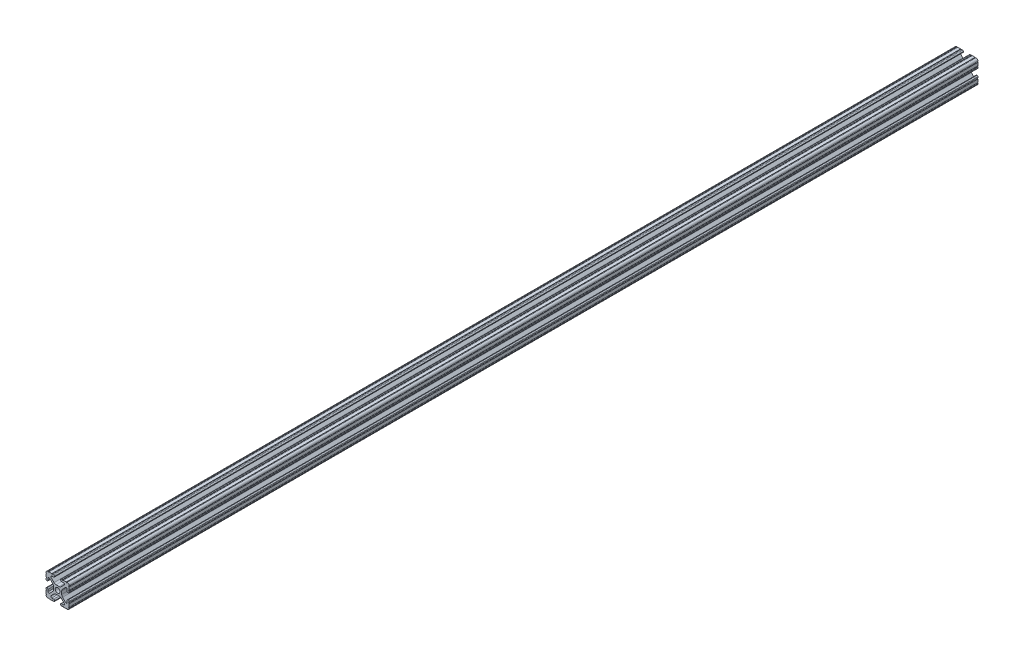
from build123d import *

# Parameters (mm, degrees)
SKETCH1_R           = 2.6035
BOSS_EXTRUDE1_DEPTH = 497.9


with BuildPart() as part:
    # Sketch1 → Boss-Extrude1 (new body, symmetric)
    with BuildSketch(Plane.XY):
        with BuildLine():
            Line((-7.179650497, -8.645192506), (-3.952270251, -5.423690499))
            ThreePointArc((-3.952270251, -5.423690499), (-2.922936451, -4.736929036), (-1.709253557, -4.4958))
            Line((-1.709253557, -4.4958), (1.709253557, -4.4958))
            ThreePointArc((1.709253557, -4.4958), (2.922936451, -4.736929036), (3.952270251, -5.423690499))
            Line((3.952270251, -5.423690499), (7.179650497, -8.645192506))
            ThreePointArc((7.179650497, -8.645192506), (7.41473083, -9.822813117), (6.416408329, -10.4902))
            Line((6.416408329, -10.4902), (4.287512407, -10.4902))
            ThreePointArc((4.287512407, -10.4902), (3.54574862, -10.79744862), (3.2385, -11.539212407))
            Line((3.2385, -11.539212407), (3.2385, -11.650987593))
            ThreePointArc((3.2385, -11.650987593), (3.54574862, -12.39275138), (4.287512407, -12.7))
            Line((4.287512407, -12.7), (5.317126718, -12.7))
            ThreePointArc((5.317126718, -12.7), (5.825126718, -12.192), (6.333126718, -12.7))
            Line((6.333126718, -12.7), (9.550443118, -12.7))
            ThreePointArc((9.550443118, -12.7), (10.058366869, -12.192000006), (10.566443095, -12.699847501))
            ThreePointArc((10.566443095, -12.699847501), (12.082537762, -12.08250727), (12.699846982, -10.566399977))
            ThreePointArc((12.699846982, -10.566399977), (12.192000006, -10.058323491), (12.7, -9.5504))
            Line((12.7, -9.5504), (12.7, -6.3330836))
            ThreePointArc((12.7, -6.3330836), (12.192, -5.8250836), (12.7, -5.3170836))
            Line((12.7, -5.3170836), (12.7, -4.287469289))
            ThreePointArc((12.7, -4.287469289), (12.39275138, -3.545705502), (11.650987593, -3.238456882))
            Line((11.650987593, -3.238456882), (11.539212407, -3.238456882))
            ThreePointArc((11.539212407, -3.238456882), (10.79744862, -3.545705502), (10.4902, -4.287469289))
            Line((10.4902, -4.287469289), (10.4902, -6.402089023))
            ThreePointArc((10.4902, -6.402089023), (9.856505071, -7.351067942), (8.737131347, -7.129408934))
            Line((8.737131347, -7.129408934), (5.441005833, -3.840816462))
            ThreePointArc((5.441005833, -3.840816462), (4.750877967, -2.809883091), (4.5085, -1.593185507))
            Line((4.5085, -1.593185507), (4.5085, 1.593185507))
            ThreePointArc((4.5085, 1.593185507), (4.750877967, 2.809883091), (5.441005833, 3.840816462))
            Line((5.441005833, 3.840816462), (8.737131347, 7.129408934))
            ThreePointArc((8.737131347, 7.129408934), (9.856505071, 7.351067942), (10.4902, 6.402089023))
            Line((10.4902, 6.402089023), (10.4902, 4.287469289))
            ThreePointArc((10.4902, 4.287469289), (10.79744862, 3.545705502), (11.539212407, 3.238456882))
            Line((11.539212407, 3.238456882), (11.650987593, 3.238456882))
            ThreePointArc((11.650987593, 3.238456882), (12.39275138, 3.545705502), (12.7, 4.287469289))
            Line((12.7, 4.287469289), (12.7, 5.3170836))
            ThreePointArc((12.7, 5.3170836), (12.192, 5.8250836), (12.7, 6.3330836))
            Line((12.7, 6.3330836), (12.7, 9.5504))
            ThreePointArc((12.7, 9.5504), (12.192000006, 10.058323491), (12.699846982, 10.566399977))
            ThreePointArc((12.699846982, 10.566399977), (12.082537762, 12.08250727), (10.566443095, 12.699847501))
            ThreePointArc((10.566443095, 12.699847501), (10.058366869, 12.192000006), (9.550443118, 12.7))
            Line((9.550443118, 12.7), (6.333126718, 12.7))
            ThreePointArc((6.333126718, 12.7), (5.825126718, 12.192), (5.317126718, 12.7))
            Line((5.317126718, 12.7), (4.287512407, 12.7))
            ThreePointArc((4.287512407, 12.7), (3.54574862, 12.39275138), (3.2385, 11.650987593))
            Line((3.2385, 11.650987593), (3.2385, 11.539212407))
            ThreePointArc((3.2385, 11.539212407), (3.54574862, 10.79744862), (4.287512407, 10.4902))
            Line((4.287512407, 10.4902), (6.476788598, 10.4902))
            ThreePointArc((6.476788598, 10.4902), (7.432222385, 9.85140422), (7.207036008, 8.724370562))
            Line((7.207036008, 8.724370562), (3.898272566, 5.423169045))
            ThreePointArc((3.898272566, 5.423169045), (2.869120213, 4.736787962), (1.655778399, 4.4958))
            Line((1.655778399, 4.4958), (-1.655778399, 4.4958))
            ThreePointArc((-1.655778399, 4.4958), (-2.869120213, 4.736787962), (-3.898272566, 5.423169045))
            Line((-3.898272566, 5.423169045), (-7.207036008, 8.724370562))
            ThreePointArc((-7.207036008, 8.724370562), (-7.432222385, 9.85140422), (-6.476788598, 10.4902))
            Line((-6.476788598, 10.4902), (-4.287512407, 10.4902))
            ThreePointArc((-4.287512407, 10.4902), (-3.54574862, 10.79744862), (-3.2385, 11.539212407))
            Line((-3.2385, 11.539212407), (-3.2385, 11.650987593))
            ThreePointArc((-3.2385, 11.650987593), (-3.54574862, 12.39275138), (-4.287512407, 12.7))
            Line((-4.287512407, 12.7), (-5.317126718, 12.7))
            ThreePointArc((-5.317126718, 12.7), (-5.825126718, 12.192), (-6.333126718, 12.7))
            Line((-6.333126718, 12.7), (-9.550443118, 12.7))
            ThreePointArc((-9.550443118, 12.7), (-10.058366869, 12.192000006), (-10.566443095, 12.699847501))
            ThreePointArc((-10.566443095, 12.699847501), (-12.082537762, 12.08250727), (-12.699846982, 10.566399977))
            ThreePointArc((-12.699846982, 10.566399977), (-12.192000006, 10.058323491), (-12.7, 9.5504))
            Line((-12.7, 9.5504), (-12.7, 6.3330836))
            ThreePointArc((-12.7, 6.3330836), (-12.192, 5.8250836), (-12.7, 5.3170836))
            Line((-12.7, 5.3170836), (-12.7, 4.287469289))
            ThreePointArc((-12.7, 4.287469289), (-12.39275138, 3.545705502), (-11.650987593, 3.238456882))
            Line((-11.650987593, 3.238456882), (-11.539212407, 3.238456882))
            ThreePointArc((-11.539212407, 3.238456882), (-10.79744862, 3.545705502), (-10.4902, 4.287469289))
            Line((-10.4902, 4.287469289), (-10.4902, 6.402089023))
            ThreePointArc((-10.4902, 6.402089023), (-9.856505071, 7.351067942), (-8.737131347, 7.129408934))
            Line((-8.737131347, 7.129408934), (-5.441005833, 3.840816462))
            ThreePointArc((-5.441005833, 3.840816462), (-4.750877967, 2.809883091), (-4.5085, 1.593185507))
            Line((-4.5085, 1.593185507), (-4.5085, -1.593185507))
            ThreePointArc((-4.5085, -1.593185507), (-4.750877967, -2.809883091), (-5.441005833, -3.840816462))
            Line((-5.441005833, -3.840816462), (-8.737131347, -7.129408934))
            ThreePointArc((-8.737131347, -7.129408934), (-9.856505071, -7.351067942), (-10.4902, -6.402089023))
            Line((-10.4902, -6.402089023), (-10.4902, -4.287469289))
            ThreePointArc((-10.4902, -4.287469289), (-10.79744862, -3.545705502), (-11.539212407, -3.238456882))
            Line((-11.539212407, -3.238456882), (-11.650987593, -3.238456882))
            ThreePointArc((-11.650987593, -3.238456882), (-12.39275138, -3.545705502), (-12.7, -4.287469289))
            Line((-12.7, -4.287469289), (-12.7, -5.3170836))
            ThreePointArc((-12.7, -5.3170836), (-12.192, -5.8250836), (-12.7, -6.3330836))
            Line((-12.7, -6.3330836), (-12.7, -9.5504))
            ThreePointArc((-12.7, -9.5504), (-12.192000006, -10.058323491), (-12.699846982, -10.566399977))
            ThreePointArc((-12.699846982, -10.566399977), (-12.082537762, -12.08250727), (-10.566443095, -12.699847501))
            ThreePointArc((-10.566443095, -12.699847501), (-10.058366869, -12.192000006), (-9.550443118, -12.7))
            Line((-9.550443118, -12.7), (-6.333126718, -12.7))
            ThreePointArc((-6.333126718, -12.7), (-5.825126718, -12.192), (-5.317126718, -12.7))
            Line((-5.317126718, -12.7), (-4.287512407, -12.7))
            ThreePointArc((-4.287512407, -12.7), (-3.54574862, -12.39275138), (-3.2385, -11.650987593))
            Line((-3.2385, -11.650987593), (-3.2385, -11.539212407))
            ThreePointArc((-3.2385, -11.539212407), (-3.54574862, -10.79744862), (-4.287512407, -10.4902))
            Line((-4.287512407, -10.4902), (-6.416408329, -10.4902))
            ThreePointArc((-6.416408329, -10.4902), (-7.41473083, -9.822813117), (-7.179650497, -8.645192506))
        make_face()
        Circle(SKETCH1_R, mode=Mode.SUBTRACT)
    extrude(amount=BOSS_EXTRUDE1_DEPTH, both=True)


solid = part.part
